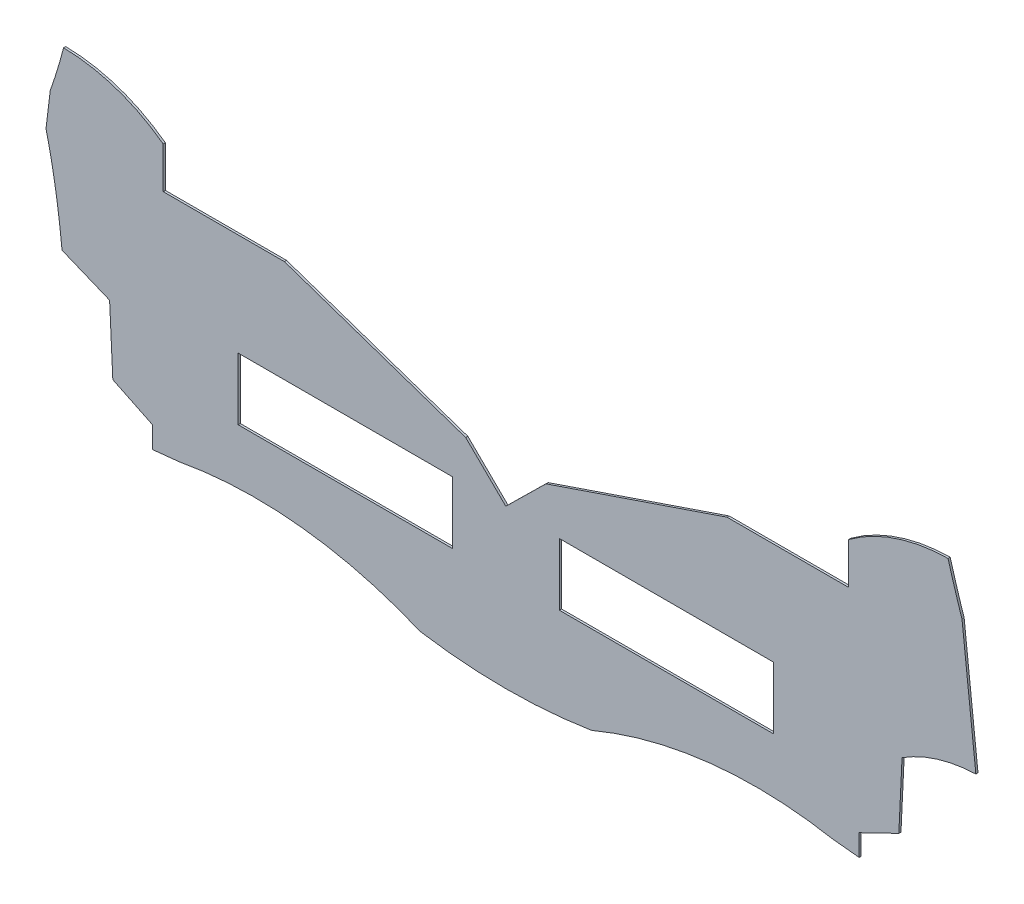
from build123d import *

# Parameters (mm, degrees)
MODEL_W                 = 10
MODEL_H                 = 2.9
SALIENTE_EXTRUIR1_DEPTH = 0.1


with BuildPart() as part:
    # Model → Saliente-Extruir1 (new body)
    with BuildSketch(Plane.XY):
        with BuildLine():
            Line((52.499211711, -23.449568352), (51.852403407, -17.50823005))
            ThreePointArc((51.852403407, -17.50823005), (51.514066846, -16.446920374), (51.199670421, -15.378274152))
            ThreePointArc((51.199670421, -15.378274152), (48.750462186, -15.793581856), (46.547094835, -16.940871612))
            Line((46.547094835, -16.940871612), (46.547094835, -18.870761499))
            Line((46.547094835, -18.870761499), (40.879134721, -18.870761499))
            Line((40.879134721, -18.870761499), (32.422332148, -21.750227381))
            Line((32.422332148, -21.750227381), (30.547210979, -23.594207383))
            Line((30.547210979, -23.594207383), (28.671677185, -21.750405519))
            Line((28.671677185, -21.750405519), (20.211717743, -18.870761499))
            Line((20.211717743, -18.870761499), (14.547094835, -18.870761499))
            Line((14.547094835, -18.870761499), (14.546457721, -16.942391482))
            ThreePointArc((14.546457721, -16.942391482), (12.342981399, -15.795311029), (9.893733725, -15.380235977))
            ThreePointArc((9.893733725, -15.380235977), (9.604749494, -16.409428161), (9.269450082, -17.424476307))
            Line((9.269450082, -17.424476307), (9.072855224, -19.069961888))
            Line((9.072855224, -19.069961888), (9.078043018, -19.091143739))
            Line((9.078043018, -19.091143739), (9.083217243, -19.112350984))
            Line((9.083217243, -19.112350984), (9.088377899, -19.133583624))
            Line((9.088377899, -19.133583624), (9.093524986, -19.154841659))
            Line((9.093524986, -19.154841659), (9.098658503, -19.176125088))
            Line((9.098658503, -19.176125088), (9.103778452, -19.197433912))
            Line((9.103778452, -19.197433912), (9.108884831, -19.21876813))
            Line((9.108884831, -19.21876813), (9.113977641, -19.240127743))
            Line((9.113977641, -19.240127743), (9.119056882, -19.26151275))
            Line((9.119056882, -19.26151275), (9.124122554, -19.282923152))
            Line((9.124122554, -19.282923152), (9.129174657, -19.304358948))
            Line((9.129174657, -19.304358948), (9.134213191, -19.325820139))
            Line((9.134213191, -19.325820139), (9.139238155, -19.347306725))
            Line((9.139238155, -19.347306725), (9.144249551, -19.368818705))
            Line((9.144249551, -19.368818705), (9.149247377, -19.390356079))
            Line((9.149247377, -19.390356079), (9.154231634, -19.411918849))
            Line((9.154231634, -19.411918849), (9.159202322, -19.433507012))
            Line((9.159202322, -19.433507012), (9.164159441, -19.455120571))
            Line((9.164159441, -19.455120571), (9.169102991, -19.476759524))
            Line((9.169102991, -19.476759524), (9.174032971, -19.498423871))
            Line((9.174032971, -19.498423871), (9.178949383, -19.520113613))
            Line((9.178949383, -19.520113613), (9.183852225, -19.54182875))
            Line((9.183852225, -19.54182875), (9.188741498, -19.563569281))
            Line((9.188741498, -19.563569281), (9.193617202, -19.585335206))
            Line((9.193617202, -19.585335206), (9.198479337, -19.607126527))
            Line((9.198479337, -19.607126527), (9.203327903, -19.628943241))
            Line((9.203327903, -19.628943241), (9.208162899, -19.650785351))
            Line((9.208162899, -19.650785351), (9.212984327, -19.672652855))
            Line((9.212984327, -19.672652855), (9.217792185, -19.694545753))
            Line((9.217792185, -19.694545753), (9.222586474, -19.716464046))
            Line((9.222586474, -19.716464046), (9.227367195, -19.738407734))
            Line((9.227367195, -19.738407734), (9.232134345, -19.760376816))
            Line((9.232134345, -19.760376816), (9.236887927, -19.782371293))
            Line((9.236887927, -19.782371293), (9.24162794, -19.804391164))
            Line((9.24162794, -19.804391164), (9.246354384, -19.82643643))
            Line((9.246354384, -19.82643643), (9.251067258, -19.84850709))
            Line((9.251067258, -19.84850709), (9.255766563, -19.870603145))
            Line((9.255766563, -19.870603145), (9.260452299, -19.892724594))
            Line((9.260452299, -19.892724594), (9.265124466, -19.914871439))
            Line((9.265124466, -19.914871439), (9.269783064, -19.937043677))
            Line((9.269783064, -19.937043677), (9.274428093, -19.95924131))
            Line((9.274428093, -19.95924131), (9.279059553, -19.981464338))
            Line((9.279059553, -19.981464338), (9.283677443, -20.00371276))
            Line((9.283677443, -20.00371276), (9.288281765, -20.025986577))
            Line((9.288281765, -20.025986577), (9.292872517, -20.048285789))
            Line((9.292872517, -20.048285789), (9.2974497, -20.070610395))
            Line((9.2974497, -20.070610395), (9.302013314, -20.092960395))
            Line((9.302013314, -20.092960395), (9.306563359, -20.11533579))
            Line((9.306563359, -20.11533579), (9.311099834, -20.13773658))
            Line((9.311099834, -20.13773658), (9.315622741, -20.160162764))
            Line((9.315622741, -20.160162764), (9.320132078, -20.182614343))
            Line((9.320132078, -20.182614343), (9.324627846, -20.205091316))
            Line((9.324627846, -20.205091316), (9.329110046, -20.227593684))
            Line((9.329110046, -20.227593684), (9.333578676, -20.250121446))
            Line((9.333578676, -20.250121446), (9.338033736, -20.272674603))
            Line((9.338033736, -20.272674603), (9.342475228, -20.295253155))
            Line((9.342475228, -20.295253155), (9.346903151, -20.317857101))
            Line((9.346903151, -20.317857101), (9.351317504, -20.340486442))
            Line((9.351317504, -20.340486442), (9.355718289, -20.363141177))
            Line((9.355718289, -20.363141177), (9.360105504, -20.385821307))
            Line((9.360105504, -20.385821307), (9.36447915, -20.408526831))
            Line((9.36447915, -20.408526831), (9.368839227, -20.43125775))
            Line((9.368839227, -20.43125775), (9.373185735, -20.454014064))
            Line((9.373185735, -20.454014064), (9.377518673, -20.476795772))
            Line((9.377518673, -20.476795772), (9.381838043, -20.499602874))
            Line((9.381838043, -20.499602874), (9.386143843, -20.522435371))
            Line((9.386143843, -20.522435371), (9.390436074, -20.545293263))
            Line((9.390436074, -20.545293263), (9.394714737, -20.568176549))
            Line((9.394714737, -20.568176549), (9.39897983, -20.59108523))
            Line((9.39897983, -20.59108523), (9.403231353, -20.614019306))
            Line((9.403231353, -20.614019306), (9.407469308, -20.636978775))
            Line((9.407469308, -20.636978775), (9.411693694, -20.65996364))
            Line((9.411693694, -20.65996364), (9.41590451, -20.682973899))
            Line((9.41590451, -20.682973899), (9.420101757, -20.706009553))
            Line((9.420101757, -20.706009553), (9.424285436, -20.729070601))
            Line((9.424285436, -20.729070601), (9.428455545, -20.752157044))
            Line((9.428455545, -20.752157044), (9.432612085, -20.775268881))
            Line((9.432612085, -20.775268881), (9.436755055, -20.798406113))
            Line((9.436755055, -20.798406113), (9.440884457, -20.821568739))
            Line((9.440884457, -20.821568739), (9.44500029, -20.84475676))
            Line((9.44500029, -20.84475676), (9.449102553, -20.867970176))
            Line((9.449102553, -20.867970176), (9.453191247, -20.891208986))
            Line((9.453191247, -20.891208986), (9.457266372, -20.91447319))
            Line((9.457266372, -20.91447319), (9.461327928, -20.93776279))
            Line((9.461327928, -20.93776279), (9.465375915, -20.961077783))
            Line((9.465375915, -20.961077783), (9.469410333, -20.984418172))
            Line((9.469410333, -20.984418172), (9.473431181, -21.007783955))
            Line((9.473431181, -21.007783955), (9.477438461, -21.031175132))
            Line((9.477438461, -21.031175132), (9.481432171, -21.054591704))
            Line((9.481432171, -21.054591704), (9.485412312, -21.078033671))
            Line((9.485412312, -21.078033671), (9.489378884, -21.101501032))
            Line((9.489378884, -21.101501032), (9.493331887, -21.124993787))
            Line((9.493331887, -21.124993787), (9.497271321, -21.148511938))
            Line((9.497271321, -21.148511938), (9.501197186, -21.172055482))
            Line((9.501197186, -21.172055482), (9.505109481, -21.195624422))
            Line((9.505109481, -21.195624422), (9.509008207, -21.219218756))
            Line((9.509008207, -21.219218756), (9.512893365, -21.242838484))
            Line((9.512893365, -21.242838484), (9.516764953, -21.266483607))
            Line((9.516764953, -21.266483607), (9.520622972, -21.290154125))
            Line((9.520622972, -21.290154125), (9.524467421, -21.313850037))
            Line((9.524467421, -21.313850037), (9.528298302, -21.337571344))
            Line((9.528298302, -21.337571344), (9.532115614, -21.361318045))
            Line((9.532115614, -21.361318045), (9.535919356, -21.385090141))
            Line((9.535919356, -21.385090141), (9.539709529, -21.408887631))
            Line((9.539709529, -21.408887631), (9.543486134, -21.432710516))
            Line((9.543486134, -21.432710516), (9.547249169, -21.456558795))
            Line((9.547249169, -21.456558795), (9.550998634, -21.480432469))
            Line((9.550998634, -21.480432469), (9.554734531, -21.504331538))
            Line((9.554734531, -21.504331538), (9.558456859, -21.528256001))
            Line((9.558456859, -21.528256001), (9.562165617, -21.552205859))
            Line((9.562165617, -21.552205859), (9.565860807, -21.576181111))
            Line((9.565860807, -21.576181111), (9.569542427, -21.600181758))
            Line((9.569542427, -21.600181758), (9.573210478, -21.6242078))
            Line((9.573210478, -21.6242078), (9.57686496, -21.648259236))
            Line((9.57686496, -21.648259236), (9.580505873, -21.672336066))
            Line((9.580505873, -21.672336066), (9.584133216, -21.696438291))
            Line((9.584133216, -21.696438291), (9.587746991, -21.720565911))
            Line((9.587746991, -21.720565911), (9.591347196, -21.744718925))
            Line((9.591347196, -21.744718925), (9.594933833, -21.768897334))
            Line((9.594933833, -21.768897334), (9.5985069, -21.793101137))
            Line((9.5985069, -21.793101137), (9.602066398, -21.817330335))
            Line((9.602066398, -21.817330335), (9.605612327, -21.841584927))
            Line((9.605612327, -21.841584927), (9.609144686, -21.865864914))
            Line((9.609144686, -21.865864914), (9.612663477, -21.890170296))
            Line((9.612663477, -21.890170296), (9.616168698, -21.914501072))
            Line((9.616168698, -21.914501072), (9.619660351, -21.938857243))
            Line((9.619660351, -21.938857243), (9.623138434, -21.963238808))
            Line((9.623138434, -21.963238808), (9.626602948, -21.987645768))
            Line((9.626602948, -21.987645768), (9.630053893, -22.012078122))
            Line((9.630053893, -22.012078122), (9.633491269, -22.036535871))
            Line((9.633491269, -22.036535871), (9.636915075, -22.061019014))
            Line((9.636915075, -22.061019014), (9.640325313, -22.085527553))
            Line((9.640325313, -22.085527553), (9.643721981, -22.110061485))
            Line((9.643721981, -22.110061485), (9.64710508, -22.134620812))
            Line((9.64710508, -22.134620812), (9.650474611, -22.159205534))
            Line((9.650474611, -22.159205534), (9.653830572, -22.18381565))
            Line((9.653830572, -22.18381565), (9.657172963, -22.208451161))
            Line((9.657172963, -22.208451161), (9.660501786, -22.233112066))
            Line((9.660501786, -22.233112066), (9.66381704, -22.257798366))
            Line((9.66381704, -22.257798366), (9.667118724, -22.282510061))
            Line((9.667118724, -22.282510061), (9.670406839, -22.30724715))
            Line((9.670406839, -22.30724715), (9.673681386, -22.332009634))
            Line((9.673681386, -22.332009634), (9.676942363, -22.356797512))
            Line((9.676942363, -22.356797512), (9.680189771, -22.381610784))
            Line((9.680189771, -22.381610784), (9.683423609, -22.406449452))
            Line((9.683423609, -22.406449452), (9.686643879, -22.431313514))
            Line((9.686643879, -22.431313514), (9.689850579, -22.45620297))
            Line((9.689850579, -22.45620297), (9.693043711, -22.481117821))
            Line((9.693043711, -22.481117821), (9.696223273, -22.506058066))
            Line((9.696223273, -22.506058066), (9.699389266, -22.531023707))
            Line((9.699389266, -22.531023707), (9.70254169, -22.556014741))
            Line((9.70254169, -22.556014741), (9.705680545, -22.58103117))
            Line((9.705680545, -22.58103117), (9.708805831, -22.606072994))
            Line((9.708805831, -22.606072994), (9.711917547, -22.631140212))
            Line((9.711917547, -22.631140212), (9.715015695, -22.656232825))
            Line((9.715015695, -22.656232825), (9.718100273, -22.681350833))
            Line((9.718100273, -22.681350833), (9.721171282, -22.706494235))
            Line((9.721171282, -22.706494235), (9.724228722, -22.731663031))
            Line((9.724228722, -22.731663031), (9.727272593, -22.756857222))
            Line((9.727272593, -22.756857222), (9.730302895, -22.782076808))
            Line((9.730302895, -22.782076808), (9.733319627, -22.807321788))
            Line((9.733319627, -22.807321788), (9.736322791, -22.832592163))
            Line((9.736322791, -22.832592163), (9.739312385, -22.857887933))
            Line((9.739312385, -22.857887933), (9.74228841, -22.883209096))
            Line((9.74228841, -22.883209096), (9.745250867, -22.908555655))
            Line((9.745250867, -22.908555655), (9.748199753, -22.933927608))
            Line((9.748199753, -22.933927608), (9.751135071, -22.959324956))
            Line((9.751135071, -22.959324956), (9.75405682, -22.984747698))
            Line((9.75405682, -22.984747698), (9.756965, -23.010195834))
            Line((9.756965, -23.010195834), (9.75985961, -23.035669366))
            Line((9.75985961, -23.035669366), (9.762740651, -23.061168291))
            Line((9.762740651, -23.061168291), (9.765608123, -23.086692612))
            Line((9.765608123, -23.086692612), (9.768462026, -23.112242327))
            Line((9.768462026, -23.112242327), (9.77130236, -23.137817436))
            Line((9.77130236, -23.137817436), (9.774129125, -23.16341794))
            Line((9.774129125, -23.16341794), (9.776942321, -23.189043839))
            Line((9.776942321, -23.189043839), (9.779741947, -23.214695132))
            Line((9.779741947, -23.214695132), (9.782528004, -23.24037182))
            Line((9.782528004, -23.24037182), (9.785300493, -23.266073902))
            Line((9.785300493, -23.266073902), (9.788059412, -23.291801379))
            Line((9.788059412, -23.291801379), (9.790804762, -23.31755425))
            Line((9.790804762, -23.31755425), (9.793536542, -23.343332516))
            Line((9.793536542, -23.343332516), (9.796254754, -23.369136177))
            Line((9.796254754, -23.369136177), (9.798959397, -23.394965232))
            Line((9.798959397, -23.394965232), (9.80165047, -23.420819682))
            Line((9.80165047, -23.420819682), (9.804327974, -23.446699526))
            Line((9.804327974, -23.446699526), (9.806991909, -23.472604765))
            Line((9.806991909, -23.472604765), (9.809642275, -23.498535398))
            Line((9.809642275, -23.498535398), (9.812279072, -23.524491426))
            Line((9.812279072, -23.524491426), (9.8149023, -23.550472848))
            Line((9.8149023, -23.550472848), (9.817511959, -23.576479665))
            Line((9.817511959, -23.576479665), (9.820108048, -23.602511877))
            Line((9.820108048, -23.602511877), (12.043351043, -24.513191756))
            Line((12.043351043, -24.513191756), (12.193242757, -27.651251827))
            Line((12.193242757, -27.651251827), (14.049768795, -28.551209913))
            Line((14.049768795, -28.551209913), (14.04991514, -29.551209903))
            Line((14.04991514, -29.551209903), (15.275444878, -29.425034352))
            ThreePointArc((15.275444878, -29.425034352), (21.000201799, -29.215766334), (26.544226025, -30.65813601))
            ThreePointArc((26.544226025, -30.65813601), (30.547980513, -30.974778541), (34.551688619, -30.657550086))
            ThreePointArc((34.551688619, -30.657550086), (40.095501703, -29.214369087), (45.820289187, -29.422799317))
            Line((45.820289187, -29.422799317), (47.045837378, -29.548795516))
            Line((47.045837378, -29.548795516), (47.045837378, -28.548795516))
            Line((47.045837378, -28.548795516), (48.902231692, -27.648565747))
            Line((48.902231692, -27.648565747), (49.051664167, -24.510483774))
            ThreePointArc((49.051664167, -24.510483774), (50.704384041, -23.74912953), (52.499211711, -23.449568352))
        make_face()
        with Locations((38.047094835, -25.098795516)):
            Rectangle(MODEL_W, MODEL_H, mode=Mode.SUBTRACT)
        with Locations((23.047094835, -25.098795516)):
            Rectangle(MODEL_W, MODEL_H, mode=Mode.SUBTRACT)
    extrude(amount=SALIENTE_EXTRUIR1_DEPTH)


solid = part.part
